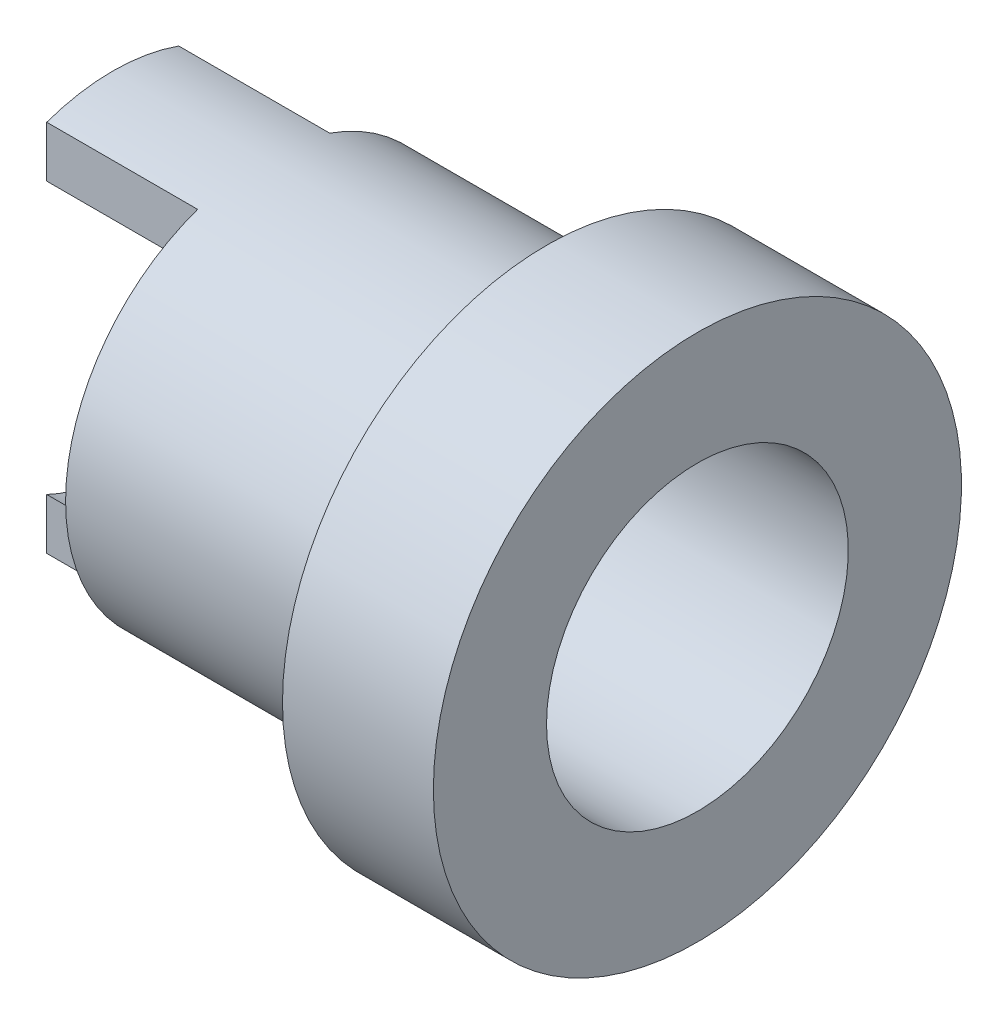
from build123d import *

# Parameters (mm, degrees)
SKETCH2_W          = 3.5
SKETCH2_H          = 9.899494936
CUT_EXTRUDE1_DEPTH = 4


with BuildPart() as part:
    # Sketch1 → Revolve1 (revolve)
    with BuildSketch(Plane(origin=(0, 0, 0), x_dir=(1, 0, 0), z_dir=(0, 1, 0))):
        Polygon((0, 4), (0, 7), (-4, 7), (-4, 5.25), (-15.5, 5.25), (-15.5, 4), align=None)
    revolve(axis=Axis((-5.134665776, 0, 0), (1, 0, 0)))

    # Sketch2 → Cut-Extrude1 (cut)
    with BuildSketch(Plane.ZY.offset(15.5)):
        with Locations((-3.5, 0)):
            Rectangle(SKETCH2_W, SKETCH2_H)
        with Locations((3.5, 0)):
            Rectangle(SKETCH2_W, SKETCH2_H)
    extrude(amount=-CUT_EXTRUDE1_DEPTH, mode=Mode.SUBTRACT)


solid = part.part
